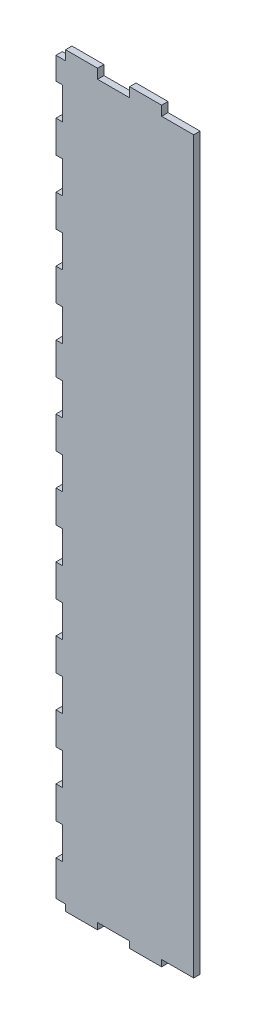
from build123d import *

# Parameters (mm, degrees)
SKETCH1_W               = 40
SKETCH1_H               = 227
BOSS_EXTRUDE1_DEPTH     = 2
SKETCH2_W               = 10
SKETCH2_H               = 2
BOSS_EXTRUDE2_DEPTH     = 3
LPATTERN1_COUNT         = 2
LPATTERN1_PITCH         = 20
SKETCH3_W               = 10
SKETCH3_H               = 2
BOSS_EXTRUDE3_DEPTH     = 3
LPATTERN2_COUNT         = 2
LPATTERN2_PITCH         = 20
SKETCH4_W               = 2
SKETCH4_H               = 10
BOSS_EXTRUDE4_DEPTH     = 3
LPATTERN3_COUNT         = 12
LPATTERN3_PITCH         = 20
ESQUISSE1_W             = 3
ESQUISSE1_H             = 3
ENL_V_MAT_EXTRU_1_DEPTH = 3
ESQUISSE2_W             = 1
ESQUISSE2_H             = 227
ESQUISSE2_W_2           = 43
ESQUISSE2_H_2           = 1
BOSS_EXTRU_1_DEPTH      = 2


with BuildPart() as part:
    # Sketch1 → Boss-Extrude1 (new body)
    with BuildSketch(Plane.XY):
        with Locations((20, 113.5)):
            Rectangle(SKETCH1_W, SKETCH1_H)
    extrude(amount=BOSS_EXTRUDE1_DEPTH)

    # Sketch2 → Boss-Extrude2 (add)
    with BuildSketch(Plane.XZ):
        with Locations((25, 1)):
            Rectangle(SKETCH2_W, SKETCH2_H)
    boss_extrude2 = extrude(amount=BOSS_EXTRUDE2_DEPTH)

    # LPattern1: Boss-Extrude2 ×2
    with Locations(*[(-i * LPATTERN1_PITCH, 0, 0) for i in range(1, LPATTERN1_COUNT)]):
        add(boss_extrude2)

    # Sketch3 → Boss-Extrude3 (add)
    with BuildSketch(Plane(origin=(0, 227, 0), x_dir=(1, 0, 0), z_dir=(0, 1, 0))):
        with Locations((25, -1)):
            Rectangle(SKETCH3_W, SKETCH3_H)
    boss_extrude3 = extrude(amount=BOSS_EXTRUDE3_DEPTH)

    # LPattern2: Boss-Extrude3 ×2
    with Locations(*[(-i * LPATTERN2_PITCH, 0, 0) for i in range(1, LPATTERN2_COUNT)]):
        add(boss_extrude3)

    # Sketch4 → Boss-Extrude4 (add)
    with BuildSketch(Plane.ZY):
        with Locations((1, 5)):
            Rectangle(SKETCH4_W, SKETCH4_H)
    boss_extrude4 = extrude(amount=BOSS_EXTRUDE4_DEPTH)

    # LPattern3: Boss-Extrude4 ×12
    with Locations(*[(0, i * LPATTERN3_PITCH, 0) for i in range(1, LPATTERN3_COUNT)]):
        add(boss_extrude4)

    # Esquisse1 → Enlèv. mat.-Extru.1 (cut, through all)
    with BuildSketch(Plane.XY.offset(2)):
        with Locations((-1.5, 228.5)):
            Rectangle(ESQUISSE1_W, ESQUISSE1_H)
    extrude(amount=-ENL_V_MAT_EXTRU_1_DEPTH, mode=Mode.SUBTRACT)

    # Esquisse2 → Boss.-Extru.1 (add)
    with BuildSketch(Plane.XY.offset(2)):
        with Locations((-0.5, 113.5)):
            Rectangle(ESQUISSE2_W, ESQUISSE2_H)
        with Locations((18.5, -0.5)):
            Rectangle(ESQUISSE2_W_2, ESQUISSE2_H_2)
    extrude(amount=-BOSS_EXTRU_1_DEPTH)


solid = part.part
